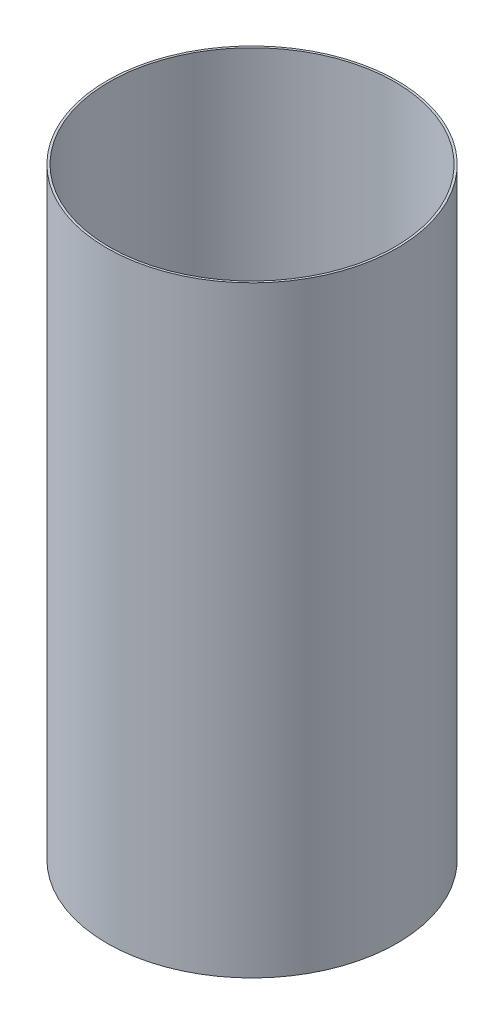
from build123d import *

# Parameters (mm, degrees)
CROQUIS1_R              = 36.15
CROQUIS1_R_2            = 35.605
SALIENTE_EXTRUIR1_DEPTH = 150


with BuildPart() as part:
    # Croquis1 → Saliente-Extruir1 (new body)
    with BuildSketch(Plane(origin=(0, 0, 0), x_dir=(1, 0, 0), z_dir=(0, 1, 0))):
        Circle(CROQUIS1_R)
        Circle(CROQUIS1_R_2, mode=Mode.SUBTRACT)
    extrude(amount=SALIENTE_EXTRUIR1_DEPTH)


solid = part.part
